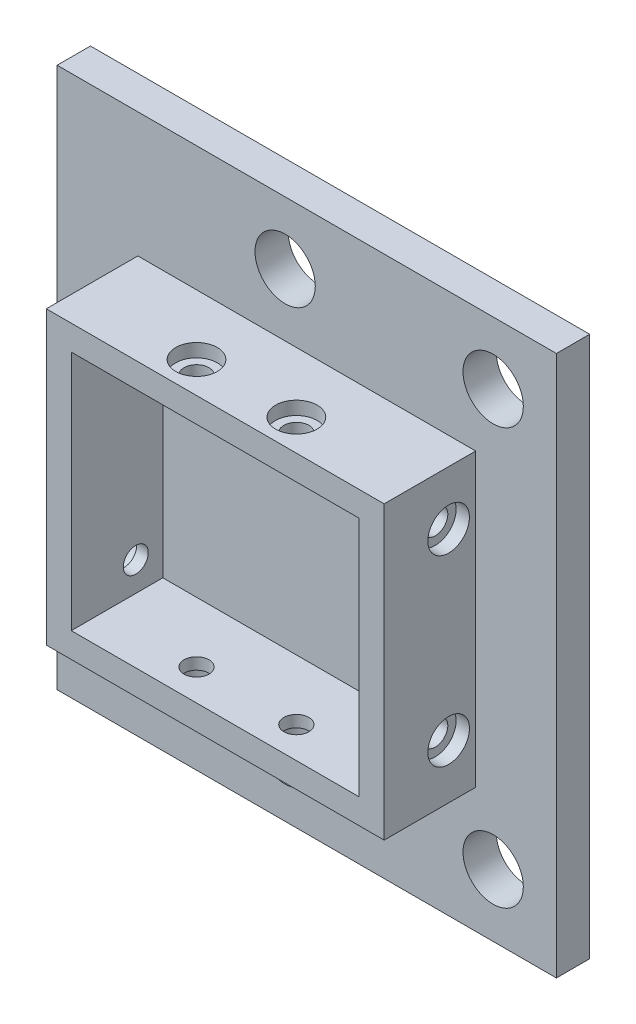
from build123d import *

# Parameters (mm, degrees)
SKETCH_1_W          = 60
SKETCH_1_H          = 65
SKETCH_1_R          = 3.625
EXTRUDE_1_DEPTH     = 4
SKETCH_2_W          = 40.6
SKETCH_2_H          = 35
SKETCH_2_W_2        = 34.6
SKETCH_2_H_2        = 29
EXTRUDE_2_DEPTH     = 11
SKETCH_3_R          = 1.5
CUT_EXTRUDE_1_DEPTH = 51
SKETCH_4_R          = 2.5
CUT_EXTRUDE_2_DEPTH = 1.6
SKETCH_5_R          = 1.5
CUT_EXTRUDE_3_DEPTH = 51.3
SKETCH_6_R          = 2.5
CUT_EXTRUDE_4_DEPTH = 1.6


with BuildPart() as part:
    # 스케치1 → 보스-돌출1 (new body)
    with BuildSketch(Plane.XY):
        Rectangle(SKETCH_1_W, SKETCH_1_H)
        with Locations((-2.6, 25)):
            Circle(SKETCH_1_R, mode=Mode.SUBTRACT)
        with Locations((-2.6, -25)):
            Circle(SKETCH_1_R, mode=Mode.SUBTRACT)
        with Locations((22.4, 25)):
            Circle(SKETCH_1_R, mode=Mode.SUBTRACT)
        with Locations((22.4, -25)):
            Circle(SKETCH_1_R, mode=Mode.SUBTRACT)
    extrude(amount=EXTRUDE_1_DEPTH)

    # 스케치2 → 보스-돌출2 (add)
    with BuildSketch(Plane.XY.offset(4)):
        Rectangle(SKETCH_2_W, SKETCH_2_H)
        Rectangle(SKETCH_2_W_2, SKETCH_2_H_2, mode=Mode.SUBTRACT)
    extrude(amount=EXTRUDE_2_DEPTH)

    # 스케치3 → 컷-돌출1 (cut, through all)
    with BuildSketch(Plane.XZ.offset(17.5)):
        with Locations((-6, 11.25)):
            Circle(SKETCH_3_R)
        with Locations((6, 11.25)):
            Circle(SKETCH_3_R)
    extrude(amount=-CUT_EXTRUDE_1_DEPTH, mode=Mode.SUBTRACT)

    # 스케치4 → 컷-돌출2 (cut)
    with BuildSketch(Plane.XZ.offset(17.5)):
        with Locations((-6, 11.25)):
            Circle(SKETCH_4_R)
        with Locations((6, 11.25)):
            Circle(SKETCH_4_R)
    cut_extrude_2 = extrude(amount=-CUT_EXTRUDE_2_DEPTH, mode=Mode.SUBTRACT)

    # 대칭 복사1: 컷-돌출2 across plane
    add(cut_extrude_2.mirror(Plane.ZX), mode=Mode.SUBTRACT)

    # 스케치5 → 컷-돌출3 (cut, through all)
    with BuildSketch(Plane.ZY.offset(20.3)):
        with Locations((7.25, -11)):
            Circle(SKETCH_5_R)
        with Locations((7.25, 11)):
            Circle(SKETCH_5_R)
    extrude(amount=-CUT_EXTRUDE_3_DEPTH, mode=Mode.SUBTRACT)

    # 스케치6 → 컷-돌출4 (cut)
    with BuildSketch(Plane.ZY.offset(20.3)):
        with Locations((7.25, 11)):
            Circle(SKETCH_6_R)
        with Locations((7.25, -11)):
            Circle(SKETCH_6_R)
    cut_extrude_4 = extrude(amount=-CUT_EXTRUDE_4_DEPTH, mode=Mode.SUBTRACT)

    # 대칭 복사2: 컷-돌출4 across plane
    add(cut_extrude_4.mirror(Plane(origin=(0, 0, 0), x_dir=(0, 0, 1), z_dir=(1, 0, 0))), mode=Mode.SUBTRACT)


solid = part.part
